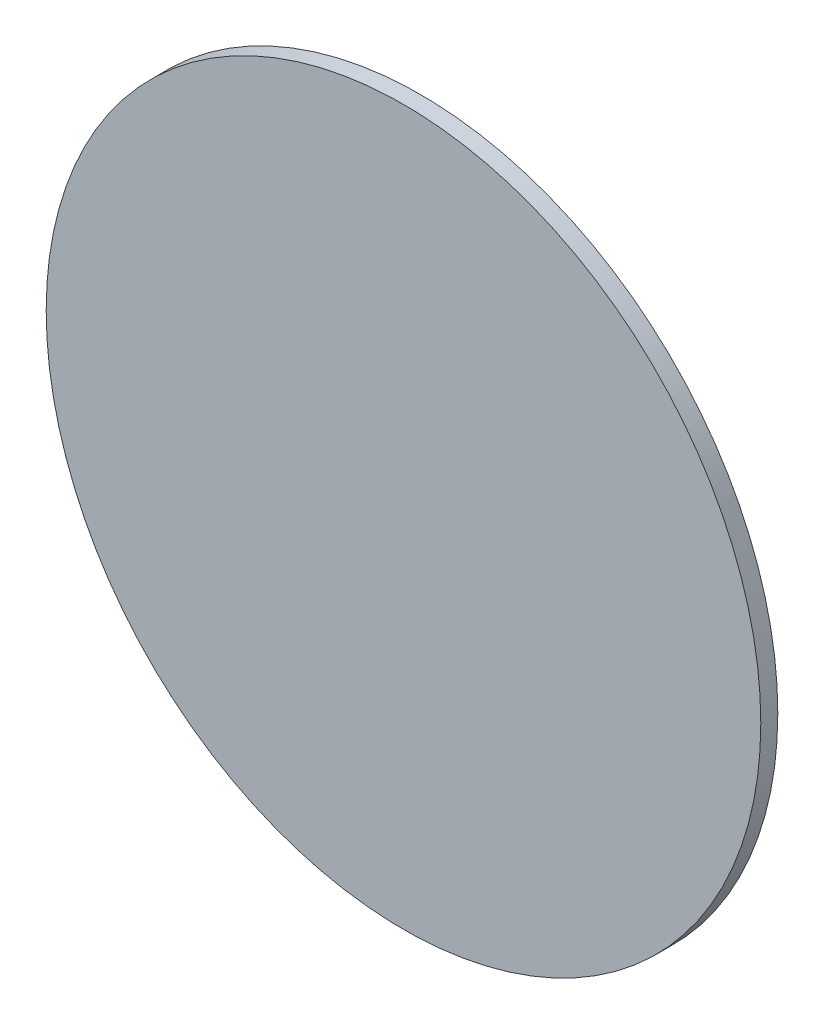
from build123d import *

# Parameters (mm, degrees)
ESBO_O1_R                = 21
RESSALTO_EXTRUS_O1_DEPTH = 1


with BuildPart() as part:
    # Esboço1 → Ressalto-extrusão1 (new body)
    with BuildSketch(Plane.XY):
        Circle(ESBO_O1_R)
    extrude(amount=RESSALTO_EXTRUS_O1_DEPTH)


solid = part.part
